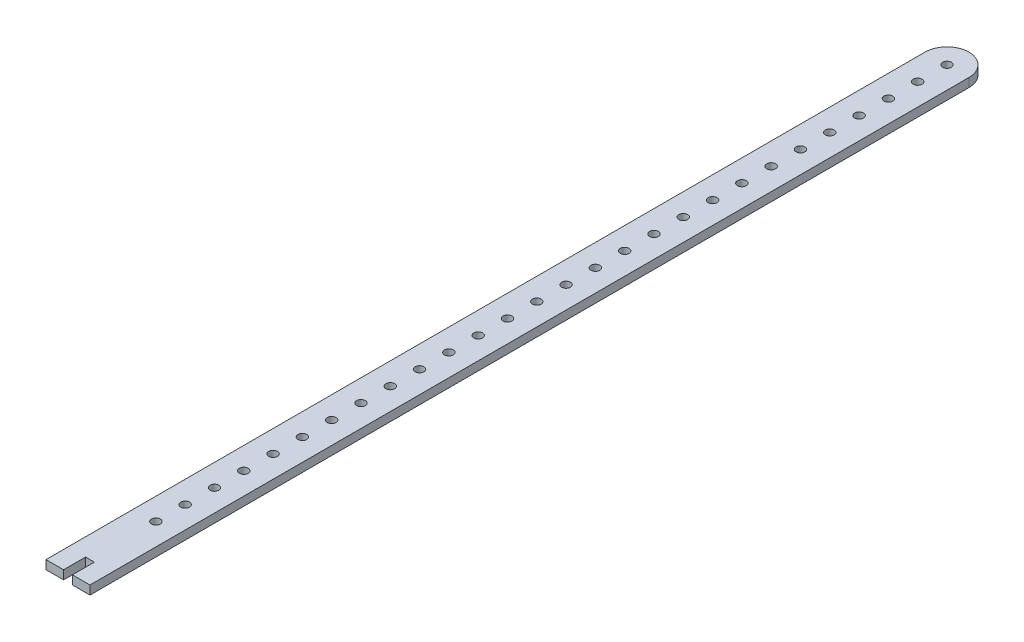
from build123d import *

# Parameters (mm, degrees)
SKETCH_1_R      = 3
EXTRUDE_1_DEPTH = 6


with BuildPart() as part:
    # Эскиз1 → Бобышка-Вытянуть1 (new body)
    with BuildSketch(Plane(origin=(0, 0, 0), x_dir=(1, 0, 0), z_dir=(0, 1, 0))):
        with BuildLine():
            Line((-15, -300), (-3, -300))
            Line((-3, -300), (-3, -285))
            Line((-3, -285), (3, -285))
            Line((3, -285), (3, -300))
            Line((3, -300), (15, -300))
            Line((15, -300), (15, 300))
            ThreePointArc((15, 300), (0, 315), (-15, 300))
            Line((-15, 300), (-15, -300))
        make_face()
        with Locations((0, 300)):
            Circle(SKETCH_1_R, mode=Mode.SUBTRACT)
        with Locations((0, 280)):
            Circle(SKETCH_1_R, mode=Mode.SUBTRACT)
        with Locations((0, 260)):
            Circle(SKETCH_1_R, mode=Mode.SUBTRACT)
        with Locations((0, 240)):
            Circle(SKETCH_1_R, mode=Mode.SUBTRACT)
        with Locations((0, 220)):
            Circle(SKETCH_1_R, mode=Mode.SUBTRACT)
        with Locations((0, 200)):
            Circle(SKETCH_1_R, mode=Mode.SUBTRACT)
        with Locations((0, 180)):
            Circle(SKETCH_1_R, mode=Mode.SUBTRACT)
        with Locations((0, 160)):
            Circle(SKETCH_1_R, mode=Mode.SUBTRACT)
        with Locations((0, 140)):
            Circle(SKETCH_1_R, mode=Mode.SUBTRACT)
        with Locations((0, 120)):
            Circle(SKETCH_1_R, mode=Mode.SUBTRACT)
        with Locations((0, 100)):
            Circle(SKETCH_1_R, mode=Mode.SUBTRACT)
        with Locations((0, 80)):
            Circle(SKETCH_1_R, mode=Mode.SUBTRACT)
        with Locations((0, 60)):
            Circle(SKETCH_1_R, mode=Mode.SUBTRACT)
        with Locations((0, 40)):
            Circle(SKETCH_1_R, mode=Mode.SUBTRACT)
        with Locations((0, 20)):
            Circle(SKETCH_1_R, mode=Mode.SUBTRACT)
        Circle(SKETCH_1_R, mode=Mode.SUBTRACT)
        with Locations((0, -20)):
            Circle(SKETCH_1_R, mode=Mode.SUBTRACT)
        with Locations((0, -40)):
            Circle(SKETCH_1_R, mode=Mode.SUBTRACT)
        with Locations((0, -60)):
            Circle(SKETCH_1_R, mode=Mode.SUBTRACT)
        with Locations((0, -80)):
            Circle(SKETCH_1_R, mode=Mode.SUBTRACT)
        with Locations((0, -100)):
            Circle(SKETCH_1_R, mode=Mode.SUBTRACT)
        with Locations((0, -120)):
            Circle(SKETCH_1_R, mode=Mode.SUBTRACT)
        with Locations((0, -140)):
            Circle(SKETCH_1_R, mode=Mode.SUBTRACT)
        with Locations((0, -160)):
            Circle(SKETCH_1_R, mode=Mode.SUBTRACT)
        with Locations((0, -180)):
            Circle(SKETCH_1_R, mode=Mode.SUBTRACT)
        with Locations((0, -200)):
            Circle(SKETCH_1_R, mode=Mode.SUBTRACT)
        with Locations((0, -220)):
            Circle(SKETCH_1_R, mode=Mode.SUBTRACT)
        with Locations((0, -240)):
            Circle(SKETCH_1_R, mode=Mode.SUBTRACT)
    extrude(amount=EXTRUDE_1_DEPTH)


solid = part.part
